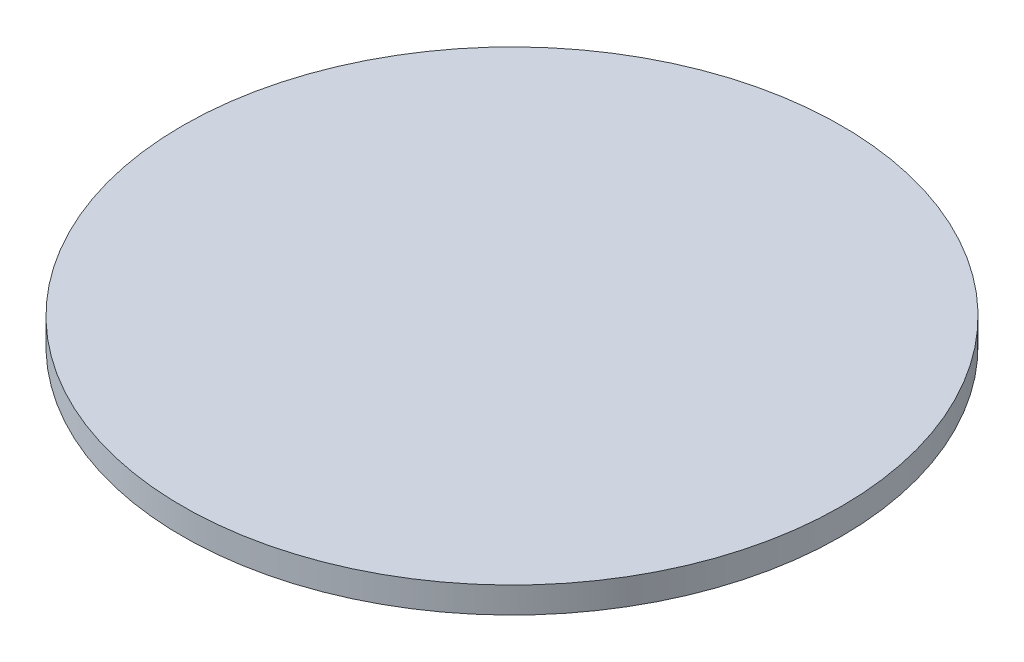
from build123d import *


with BuildPart() as part:
    # Sketch1 → Revolve1 (revolve)
    with BuildSketch(Plane.XY):
        with BuildLine():
            Line((0, 0), (0, -4))
            Line((0, -4), (30, -4))
            ThreePointArc((30, -4), (34.031128874, -3.749030993), (38, -3))
            Line((38, -3), (38, 0))
            Line((38, 0), (0, 0))
        make_face()
    revolve(axis=Axis((0, 0, 0), (0, -1, 0)))


solid = part.part
